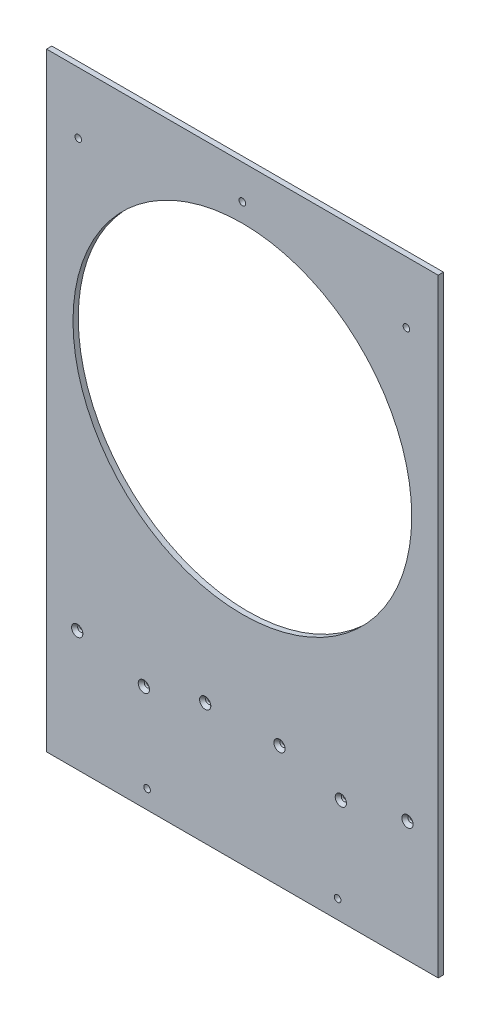
from build123d import *

# Parameters (mm, degrees)
SKETCH1_W                                     = 469.9
SKETCH1_H                                     = 2413
SKETCH1_R                                     = 203.2
BOSS_EXTRUDE1_DEPTH                           = 6.35
CSK_FOR_1_4_FLAT_HEAD_SOCKET_CAP_SCR_2_COUNT  = 2
CSK_FOR_1_4_FLAT_HEAD_SOCKET_CAP_SCR_2_PITCH  = 76.2
CSK_FOR_1_4_FLAT_HEAD_SOCKET_CAP_SCR_3_COUNT  = 2
CSK_FOR_1_4_FLAT_HEAD_SOCKET_CAP_SCR_3_PITCH  = 89.142542345
CSK_FOR_1_4_FLAT_HEAD_SOCKET_CAP_SCR_4_COUNT  = 2
CSK_FOR_1_4_FLAT_HEAD_SOCKET_CAP_SCR_4_PITCH  = 163.936718394
CSK_FOR_1_4_FLAT_HEAD_SOCKET_CAP_SCR_5_COUNT  = 2
CSK_FOR_1_4_FLAT_HEAD_SOCKET_CAP_SCR_5_PITCH  = 711.2
CSK_FOR_1_4_FLAT_HEAD_SOCKET_CAP_SCR_6_COUNT  = 2
CSK_FOR_1_4_FLAT_HEAD_SOCKET_CAP_SCR_6_PITCH  = 695.384275934
CSK_FOR_1_4_FLAT_HEAD_SOCKET_CAP_SCR_7_COUNT  = 2
CSK_FOR_1_4_FLAT_HEAD_SOCKET_CAP_SCR_7_PITCH  = 716.764837904
CSK_FOR_1_4_FLAT_HEAD_SOCKET_CAP_SCR_8_COUNT  = 2
CSK_FOR_1_4_FLAT_HEAD_SOCKET_CAP_SCR_8_PITCH  = 710.371803251
CSK_FOR_1_4_FLAT_HEAD_SOCKET_CAP_SCR_9_COUNT  = 2
CSK_FOR_1_4_FLAT_HEAD_SOCKET_CAP_SCR_9_PITCH  = 1422.4
CSK_FOR_1_4_FLAT_HEAD_SOCKET_CAP_SCR_10_COUNT = 2
CSK_FOR_1_4_FLAT_HEAD_SOCKET_CAP_SCR_10_PITCH = 1404.60778242
CSK_FOR_1_4_FLAT_HEAD_SOCKET_CAP_SCR_11_COUNT = 2
CSK_FOR_1_4_FLAT_HEAD_SOCKET_CAP_SCR_11_PITCH = 1425.190567207
CSK_FOR_1_4_FLAT_HEAD_SOCKET_CAP_SCR_12_COUNT = 2
CSK_FOR_1_4_FLAT_HEAD_SOCKET_CAP_SCR_12_PITCH = 1412.087755797
CSK_FOR_1_4_FLAT_HEAD_SOCKET_CAP_SCR_13_COUNT = 2
CSK_FOR_1_4_FLAT_HEAD_SOCKET_CAP_SCR_13_PITCH = 153.55813077
CSK_FOR_1_4_FLAT_HEAD_SOCKET_CAP_SCR_14_COUNT = 2
CSK_FOR_1_4_FLAT_HEAD_SOCKET_CAP_SCR_14_PITCH = 242.697219812
CSK_FOR_1_4_FLAT_HEAD_SOCKET_CAP_SCR_15_COUNT = 2
CSK_FOR_1_4_FLAT_HEAD_SOCKET_CAP_SCR_15_PITCH = 749.86024568
CSK_FOR_1_4_FLAT_HEAD_SOCKET_CAP_SCR_16_COUNT = 2
CSK_FOR_1_4_FLAT_HEAD_SOCKET_CAP_SCR_16_PITCH = 1441.280581843
CSK_FOR_1_4_FLAT_HEAD_SOCKET_CAP_SCR_17_COUNT = 2
CSK_FOR_1_4_FLAT_HEAD_SOCKET_CAP_SCR_17_PITCH = 1428.974413563
CSK_FOR_1_4_FLAT_HEAD_SOCKET_CAP_SCR_18_COUNT = 2
CSK_FOR_1_4_FLAT_HEAD_SOCKET_CAP_SCR_18_PITCH = 725.925992834
F_5_16_0_3125_DIAMETER_HOLE1_D                = 7.9375
SKETCH6_W                                     = 469.9
SKETCH6_H                                     = 1654.81
CUT_EXTRUDE1_DEPTH                            = 7.35
SKETCH7_W                                     = 469.9
SKETCH7_H                                     = 27.94
CUT_EXTRUDE2_DEPTH                            = 7.35


with BuildPart() as part:
    # Sketch1 → Boss-Extrude1 (new body)
    with BuildSketch(Plane.XY):
        with Locations((0, 1206.5)):
            Rectangle(SKETCH1_W, SKETCH1_H)
        with Locations((0, 695.96)):
            Circle(SKETCH1_R, mode=Mode.SUBTRACT)
        with Locations((0, 1407.16)):
            Circle(SKETCH1_R, mode=Mode.SUBTRACT)
        with Locations((0, 2118.36)):
            Circle(SKETCH1_R, mode=Mode.SUBTRACT)
    extrude(amount=BOSS_EXTRUDE1_DEPTH)

    # Sketch3 → CSK for 1/4 Flat Head Socket Cap Screw1 (revolve, cut)
    with BuildSketch(Plane(origin=(44.571271172, 378.545152647, 6.35), x_dir=(0, -1, 0), z_dir=(1, 0, 0))):
        Polygon((0, 0), (0, 6.35), (3.3782, 6.35), (3.3782, 3.871564875), (6.7437, 0), align=None)
    csk_for_1_4_flat_head_socket_cap_screw1 = revolve(axis=Axis((44.571271172, 378.545152647, 12.7), (0, 0, -1)), mode=Mode.SUBTRACT)

    # CSK for 1_4 Flat Head Socket Cap Scr 2: CSK for 1/4 Flat Head Socket Cap Screw1 ×2
    with Locations(*[Vector(0.965925826, -0.258819045, 0) * (i * CSK_FOR_1_4_FLAT_HEAD_SOCKET_CAP_SCR_2_PITCH) for i in range(1, CSK_FOR_1_4_FLAT_HEAD_SOCKET_CAP_SCR_2_COUNT)]):
        add(csk_for_1_4_flat_head_socket_cap_screw1, mode=Mode.SUBTRACT)

    # CSK for 1_4 Flat Head Socket Cap Scr 3: CSK for 1/4 Flat Head Socket Cap Screw1 ×2
    with Locations(*[(-i * CSK_FOR_1_4_FLAT_HEAD_SOCKET_CAP_SCR_3_PITCH, 0, 0) for i in range(1, CSK_FOR_1_4_FLAT_HEAD_SOCKET_CAP_SCR_3_COUNT)]):
        add(csk_for_1_4_flat_head_socket_cap_screw1, mode=Mode.SUBTRACT)

    # CSK for 1_4 Flat Head Socket Cap Scr 4: CSK for 1/4 Flat Head Socket Cap Screw1 ×2
    with Locations(*[Vector(-0.99273727, -0.120302586, 0) * (i * CSK_FOR_1_4_FLAT_HEAD_SOCKET_CAP_SCR_4_PITCH) for i in range(1, CSK_FOR_1_4_FLAT_HEAD_SOCKET_CAP_SCR_4_COUNT)]):
        add(csk_for_1_4_flat_head_socket_cap_screw1, mode=Mode.SUBTRACT)

    # CSK for 1_4 Flat Head Socket Cap Scr 5: CSK for 1/4 Flat Head Socket Cap Screw1 ×2
    with Locations(*[(0, i * CSK_FOR_1_4_FLAT_HEAD_SOCKET_CAP_SCR_5_PITCH, 0) for i in range(1, CSK_FOR_1_4_FLAT_HEAD_SOCKET_CAP_SCR_5_COUNT)]):
        add(csk_for_1_4_flat_head_socket_cap_screw1, mode=Mode.SUBTRACT)

    # CSK for 1_4 Flat Head Socket Cap Scr 6: CSK for 1/4 Flat Head Socket Cap Screw1 ×2
    with Locations(*[Vector(0.105845862, 0.994382549, 0) * (i * CSK_FOR_1_4_FLAT_HEAD_SOCKET_CAP_SCR_6_PITCH) for i in range(1, CSK_FOR_1_4_FLAT_HEAD_SOCKET_CAP_SCR_6_COUNT)]):
        add(csk_for_1_4_flat_head_socket_cap_screw1, mode=Mode.SUBTRACT)

    # CSK for 1_4 Flat Head Socket Cap Scr 7: CSK for 1/4 Flat Head Socket Cap Screw1 ×2
    with Locations(*[Vector(-0.124367907, 0.992236173, 0) * (i * CSK_FOR_1_4_FLAT_HEAD_SOCKET_CAP_SCR_7_PITCH) for i in range(1, CSK_FOR_1_4_FLAT_HEAD_SOCKET_CAP_SCR_7_COUNT)]):
        add(csk_for_1_4_flat_head_socket_cap_screw1, mode=Mode.SUBTRACT)

    # CSK for 1_4 Flat Head Socket Cap Scr 8: CSK for 1/4 Flat Head Socket Cap Screw1 ×2
    with Locations(*[Vector(-0.229099874, 0.973402922, 0) * (i * CSK_FOR_1_4_FLAT_HEAD_SOCKET_CAP_SCR_8_PITCH) for i in range(1, CSK_FOR_1_4_FLAT_HEAD_SOCKET_CAP_SCR_8_COUNT)]):
        add(csk_for_1_4_flat_head_socket_cap_screw1, mode=Mode.SUBTRACT)

    # CSK for 1_4 Flat Head Socket Cap Scr 9: CSK for 1/4 Flat Head Socket Cap Screw1 ×2
    with Locations(*[(0, i * CSK_FOR_1_4_FLAT_HEAD_SOCKET_CAP_SCR_9_PITCH, 0) for i in range(1, CSK_FOR_1_4_FLAT_HEAD_SOCKET_CAP_SCR_9_COUNT)]):
        add(csk_for_1_4_flat_head_socket_cap_screw1, mode=Mode.SUBTRACT)

    # CSK for 1_4 Flat Head Socket Cap Scr 10: CSK for 1/4 Flat Head Socket Cap Screw1 ×2
    with Locations(*[Vector(0.052401495, 0.998626098, 0) * (i * CSK_FOR_1_4_FLAT_HEAD_SOCKET_CAP_SCR_10_PITCH) for i in range(1, CSK_FOR_1_4_FLAT_HEAD_SOCKET_CAP_SCR_10_COUNT)]):
        add(csk_for_1_4_flat_head_socket_cap_screw1, mode=Mode.SUBTRACT)

    # CSK for 1_4 Flat Head Socket Cap Scr 11: CSK for 1/4 Flat Head Socket Cap Screw1 ×2
    with Locations(*[Vector(-0.062547805, 0.998041969, 0) * (i * CSK_FOR_1_4_FLAT_HEAD_SOCKET_CAP_SCR_11_PITCH) for i in range(1, CSK_FOR_1_4_FLAT_HEAD_SOCKET_CAP_SCR_11_COUNT)]):
        add(csk_for_1_4_flat_head_socket_cap_screw1, mode=Mode.SUBTRACT)

    # CSK for 1_4 Flat Head Socket Cap Scr 12: CSK for 1/4 Flat Head Socket Cap Screw1 ×2
    with Locations(*[Vector(-0.115252108, 0.993336273, 0) * (i * CSK_FOR_1_4_FLAT_HEAD_SOCKET_CAP_SCR_12_PITCH) for i in range(1, CSK_FOR_1_4_FLAT_HEAD_SOCKET_CAP_SCR_12_COUNT)]):
        add(csk_for_1_4_flat_head_socket_cap_screw1, mode=Mode.SUBTRACT)

    # CSK for 1_4 Flat Head Socket Cap Scr 13: CSK for 1/4 Flat Head Socket Cap Screw1 ×2
    with Locations(*[Vector(0.999938773, -0.011065747, 0) * (i * CSK_FOR_1_4_FLAT_HEAD_SOCKET_CAP_SCR_13_PITCH) for i in range(1, CSK_FOR_1_4_FLAT_HEAD_SOCKET_CAP_SCR_13_COUNT)]):
        add(csk_for_1_4_flat_head_socket_cap_screw1, mode=Mode.SUBTRACT)

    # CSK for 1_4 Flat Head Socket Cap Scr 14: CSK for 1/4 Flat Head Socket Cap Screw1 ×2
    with Locations(*[Vector(-0.999975489, -0.007001462, 0) * (i * CSK_FOR_1_4_FLAT_HEAD_SOCKET_CAP_SCR_14_PITCH) for i in range(1, CSK_FOR_1_4_FLAT_HEAD_SOCKET_CAP_SCR_14_COUNT)]):
        add(csk_for_1_4_flat_head_socket_cap_screw1, mode=Mode.SUBTRACT)

    # CSK for 1_4 Flat Head Socket Cap Scr 15: CSK for 1/4 Flat Head Socket Cap Screw1 ×2
    with Locations(*[Vector(-0.32364867, 0.946177329, 0) * (i * CSK_FOR_1_4_FLAT_HEAD_SOCKET_CAP_SCR_15_PITCH) for i in range(1, CSK_FOR_1_4_FLAT_HEAD_SOCKET_CAP_SCR_15_COUNT)]):
        add(csk_for_1_4_flat_head_socket_cap_screw1, mode=Mode.SUBTRACT)

    # CSK for 1_4 Flat Head Socket Cap Scr 16: CSK for 1/4 Flat Head Socket Cap Screw1 ×2
    with Locations(*[Vector(-0.168385861, 0.985721158, 0) * (i * CSK_FOR_1_4_FLAT_HEAD_SOCKET_CAP_SCR_16_PITCH) for i in range(1, CSK_FOR_1_4_FLAT_HEAD_SOCKET_CAP_SCR_16_COUNT)]):
        add(csk_for_1_4_flat_head_socket_cap_screw1, mode=Mode.SUBTRACT)

    # CSK for 1_4 Flat Head Socket Cap Scr 17: CSK for 1/4 Flat Head Socket Cap Screw1 ×2
    with Locations(*[Vector(0.107453799, 0.994210079, 0) * (i * CSK_FOR_1_4_FLAT_HEAD_SOCKET_CAP_SCR_17_PITCH) for i in range(1, CSK_FOR_1_4_FLAT_HEAD_SOCKET_CAP_SCR_17_COUNT)]):
        add(csk_for_1_4_flat_head_socket_cap_screw1, mode=Mode.SUBTRACT)

    # CSK for 1_4 Flat Head Socket Cap Scr 18: CSK for 1/4 Flat Head Socket Cap Screw1 ×2
    with Locations(*[Vector(0.211521189, 0.977373412, 0) * (i * CSK_FOR_1_4_FLAT_HEAD_SOCKET_CAP_SCR_18_PITCH) for i in range(1, CSK_FOR_1_4_FLAT_HEAD_SOCKET_CAP_SCR_18_COUNT)]):
        add(csk_for_1_4_flat_head_socket_cap_screw1, mode=Mode.SUBTRACT)

    # 5/16 (0.3125) Diameter Hole1 (through all)
    with Locations(Plane.XY.offset(6.35)):
        with Locations((-114.3, 254.635), (-114.3, 210.185), (-196.85, 177.8), (196.85, 177.8), (114.3, 210.185), (114.3, 254.635), (-114.3, 965.835), (-114.3, 921.385), (-196.85, 889), (196.85, 889), (114.3, 921.385), (114.3, 965.835), (-114.3, 1677.035), (-114.3, 1632.585), (-196.85, 1600.2), (196.85, 1600.2), (114.3, 1632.585), (114.3, 1677.035), (-196.85, 2311.4), (196.85, 2311.4), (0, 2343.785)):
            Hole(F_5_16_0_3125_DIAMETER_HOLE1_D / 2)

    # Sketch6 → Cut-Extrude1 (cut, through all)
    with BuildSketch(Plane.XY.offset(6.35)):
        with Locations((0, 827.405)):
            Rectangle(SKETCH6_W, SKETCH6_H)
    extrude(amount=-CUT_EXTRUDE1_DEPTH, mode=Mode.SUBTRACT)

    # Sketch7 → Cut-Extrude2 (cut, through all)
    with BuildSketch(Plane.XY.offset(6.35)):
        with Locations((0, 2399.03)):
            Rectangle(SKETCH7_W, SKETCH7_H)
    extrude(amount=-CUT_EXTRUDE2_DEPTH, mode=Mode.SUBTRACT)


solid = part.part
